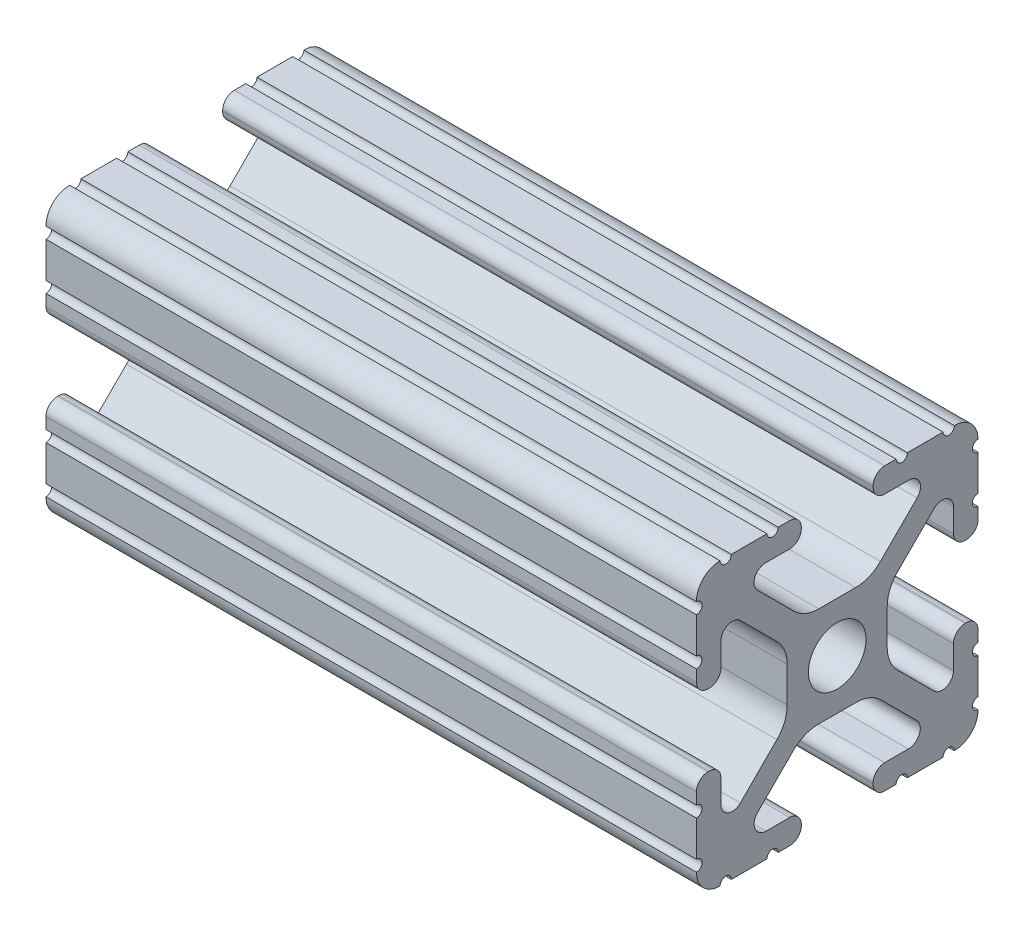
from build123d import *

# Parameters (mm, degrees)
SKETCH11_R                = 2.6035
F_10_1010_PROFILE_1_DEPTH = 58.674
SKETCH13_R                = 2.54
CUT_EXTRUDE1_DEPTH        = 66.185031073


with BuildPart() as part:
    # Sketch11 → 10 1010 PROFILE(1) (new body)
    with BuildSketch(Plane.ZY):
        with BuildLine():
            Line((-1.709253557, -4.4958), (1.709253557, -4.4958))
            ThreePointArc((1.709253557, -4.4958), (2.922935876, -4.736928798), (3.95226937, -5.423689619))
            Line((3.95226937, -5.423689619), (7.179652728, -8.645192207))
            ThreePointArc((7.179652728, -8.645192207), (7.414733441, -9.822812921), (6.41641086, -10.4902))
            Line((6.41641086, -10.4902), (4.28752, -10.4902))
            ThreePointArc((4.28752, -10.4902), (3.545750844, -10.797450844), (3.2385, -11.53922))
            Line((3.2385, -11.53922), (3.2385, -11.65098))
            ThreePointArc((3.2385, -11.65098), (3.545750844, -12.392749156), (4.28752, -12.7))
            Line((4.28752, -12.7), (5.3171344, -12.7))
            ThreePointArc((5.3171344, -12.7), (5.8251344, -12.192), (6.3331344, -12.7))
            Line((6.3331344, -12.7), (9.5504, -12.7))
            ThreePointArc((9.5504, -12.7), (10.058323491, -12.192000006), (10.566399977, -12.699846982))
            ThreePointArc((10.566399977, -12.699846982), (12.082522516, -12.082522516), (12.699846982, -10.566399977))
            ThreePointArc((12.699846982, -10.566399977), (12.192000006, -10.058323491), (12.7, -9.5504))
            Line((12.7, -9.5504), (12.7, -6.3330836))
            ThreePointArc((12.7, -6.3330836), (12.192, -5.8250836), (12.7, -5.3170836))
            Line((12.7, -5.3170836), (12.7, -4.287470133))
            ThreePointArc((12.7, -4.287470133), (12.392749156, -3.545700977), (11.65098, -3.238450133))
            Line((11.65098, -3.238450133), (11.53922, -3.238450133))
            ThreePointArc((11.53922, -3.238450133), (10.797450844, -3.545700977), (10.4902, -4.287470133))
            Line((10.4902, -4.287470133), (10.4902, -6.402089023))
            ThreePointArc((10.4902, -6.402089023), (9.856394933, -7.351113629), (8.736962546, -7.129240479))
            Line((8.736962546, -7.129240479), (5.440484187, -3.838768792))
            ThreePointArc((5.440484187, -3.838768792), (4.75073678, -2.808015636), (4.5085, -1.591658411))
            Line((4.5085, -1.591658411), (4.5085, 1.591658411))
            ThreePointArc((4.5085, 1.591658411), (4.75073678, 2.808015636), (5.440484187, 3.838768792))
            Line((5.440484187, 3.838768792), (8.736962546, 7.129240479))
            ThreePointArc((8.736962546, 7.129240479), (9.856394933, 7.351113629), (10.4902, 6.402089023))
            Line((10.4902, 6.402089023), (10.4902, 4.287470133))
            ThreePointArc((10.4902, 4.287470133), (10.797450844, 3.545700977), (11.53922, 3.238450133))
            Line((11.53922, 3.238450133), (11.65098, 3.238450133))
            ThreePointArc((11.65098, 3.238450133), (12.392749156, 3.545700977), (12.7, 4.287470133))
            Line((12.7, 4.287470133), (12.7, 5.3171344))
            ThreePointArc((12.7, 5.3171344), (12.192, 5.8251344), (12.7, 6.3331344))
            Line((12.7, 6.3331344), (12.7, 9.5504))
            ThreePointArc((12.7, 9.5504), (12.192000006, 10.058323491), (12.699846982, 10.566399977))
            ThreePointArc((12.699846982, 10.566399977), (12.082522516, 12.082522516), (10.566399977, 12.699846982))
            ThreePointArc((10.566399977, 12.699846982), (10.058323491, 12.192000006), (9.5504, 12.7))
            Line((9.5504, 12.7), (6.3330836, 12.7))
            ThreePointArc((6.3330836, 12.7), (5.8250836, 12.192), (5.3170836, 12.7))
            Line((5.3170836, 12.7), (4.2874692, 12.7))
            ThreePointArc((4.2874692, 12.7), (3.545700044, 12.392749156), (3.2384492, 11.65098))
            Line((3.2384492, 11.65098), (3.2384492, 11.53922))
            ThreePointArc((3.2384492, 11.53922), (3.545700044, 10.797450844), (4.2874692, 10.4902))
            Line((4.2874692, 10.4902), (6.476774195, 10.4902))
            ThreePointArc((6.476774195, 10.4902), (7.43216212, 9.851515102), (7.207191475, 8.724540082))
            Line((7.207191475, 8.724540082), (3.900315394, 5.423689619))
            ThreePointArc((3.900315394, 5.423689619), (2.8709819, 4.736928798), (1.657299581, 4.4958))
            Line((1.657299581, 4.4958), (-1.657299581, 4.4958))
            ThreePointArc((-1.657299581, 4.4958), (-2.8709819, 4.736928798), (-3.900315394, 5.423689619))
            Line((-3.900315394, 5.423689619), (-7.207191475, 8.724540082))
            ThreePointArc((-7.207191475, 8.724540082), (-7.43216212, 9.851515102), (-6.476774195, 10.4902))
            Line((-6.476774195, 10.4902), (-4.2874692, 10.4902))
            ThreePointArc((-4.2874692, 10.4902), (-3.545700044, 10.797450844), (-3.2384492, 11.53922))
            Line((-3.2384492, 11.53922), (-3.2384492, 11.65098))
            ThreePointArc((-3.2384492, 11.65098), (-3.545700044, 12.392749156), (-4.2874692, 12.7))
            Line((-4.2874692, 12.7), (-5.3170836, 12.7))
            ThreePointArc((-5.3170836, 12.7), (-5.8250836, 12.192), (-6.3330836, 12.7))
            Line((-6.3330836, 12.7), (-9.5504, 12.7))
            ThreePointArc((-9.5504, 12.7), (-10.058323491, 12.192000006), (-10.566399977, 12.699846982))
            ThreePointArc((-10.566399977, 12.699846982), (-12.082522516, 12.082522516), (-12.699846982, 10.566399977))
            ThreePointArc((-12.699846982, 10.566399977), (-12.192000006, 10.058323491), (-12.7, 9.5504))
            Line((-12.7, 9.5504), (-12.7, 6.3331344))
            ThreePointArc((-12.7, 6.3331344), (-12.192, 5.8251344), (-12.7, 5.3171344))
            Line((-12.7, 5.3171344), (-12.7, 4.287470133))
            ThreePointArc((-12.7, 4.287470133), (-12.392749156, 3.545700977), (-11.65098, 3.238450133))
            Line((-11.65098, 3.238450133), (-11.53922, 3.238450133))
            ThreePointArc((-11.53922, 3.238450133), (-10.797450844, 3.545700977), (-10.4902, 4.287470133))
            Line((-10.4902, 4.287470133), (-10.4902, 6.402089023))
            ThreePointArc((-10.4902, 6.402089023), (-9.856394933, 7.351113629), (-8.736962546, 7.129240479))
            Line((-8.736962546, 7.129240479), (-5.440484187, 3.838768792))
            ThreePointArc((-5.440484187, 3.838768792), (-4.75073678, 2.808015636), (-4.5085, 1.591658411))
            Line((-4.5085, 1.591658411), (-4.5085, -1.591658411))
            ThreePointArc((-4.5085, -1.591658411), (-4.75073678, -2.808015636), (-5.440484187, -3.838768792))
            Line((-5.440484187, -3.838768792), (-8.736962546, -7.129240479))
            ThreePointArc((-8.736962546, -7.129240479), (-9.856394933, -7.351113629), (-10.4902, -6.402089023))
            Line((-10.4902, -6.402089023), (-10.4902, -4.287470133))
            ThreePointArc((-10.4902, -4.287470133), (-10.797450844, -3.545700977), (-11.53922, -3.238450133))
            Line((-11.53922, -3.238450133), (-11.65098, -3.238450133))
            ThreePointArc((-11.65098, -3.238450133), (-12.392749156, -3.545700977), (-12.7, -4.287470133))
            Line((-12.7, -4.287470133), (-12.7, -5.3170836))
            ThreePointArc((-12.7, -5.3170836), (-12.192, -5.8250836), (-12.7, -6.3330836))
            Line((-12.7, -6.3330836), (-12.7, -9.5504))
            ThreePointArc((-12.7, -9.5504), (-12.192000006, -10.058323491), (-12.699846982, -10.566399977))
            ThreePointArc((-12.699846982, -10.566399977), (-12.082522516, -12.082522516), (-10.566399977, -12.699846982))
            ThreePointArc((-10.566399977, -12.699846982), (-10.058323491, -12.192000006), (-9.5504, -12.7))
            Line((-9.5504, -12.7), (-6.3331344, -12.7))
            ThreePointArc((-6.3331344, -12.7), (-5.8251344, -12.192), (-5.3171344, -12.7))
            Line((-5.3171344, -12.7), (-4.28752, -12.7))
            ThreePointArc((-4.28752, -12.7), (-3.545750844, -12.392749156), (-3.2385, -11.65098))
            Line((-3.2385, -11.65098), (-3.2385, -11.53922))
            ThreePointArc((-3.2385, -11.53922), (-3.545750844, -10.797450844), (-4.28752, -10.4902))
            Line((-4.28752, -10.4902), (-6.41641086, -10.4902))
            ThreePointArc((-6.41641086, -10.4902), (-7.414733441, -9.822812921), (-7.179652728, -8.645192207))
            Line((-7.179652728, -8.645192207), (-3.95226937, -5.423689619))
            ThreePointArc((-3.95226937, -5.423689619), (-2.922935876, -4.736928798), (-1.709253557, -4.4958))
        make_face()
        Circle(SKETCH11_R, mode=Mode.SUBTRACT)
    extrude(amount=F_10_1010_PROFILE_1_DEPTH)

    # Sketch13 → Cut-Extrude1 (cut, through all)
    with BuildSketch(Plane.XY.offset(12.7)):
        with Locations((-39.624, 0)):
            Circle(SKETCH13_R)
        with Locations((-19.05, 0)):
            Circle(SKETCH13_R)
    extrude(amount=-CUT_EXTRUDE1_DEPTH, mode=Mode.SUBTRACT)


solid = part.part
